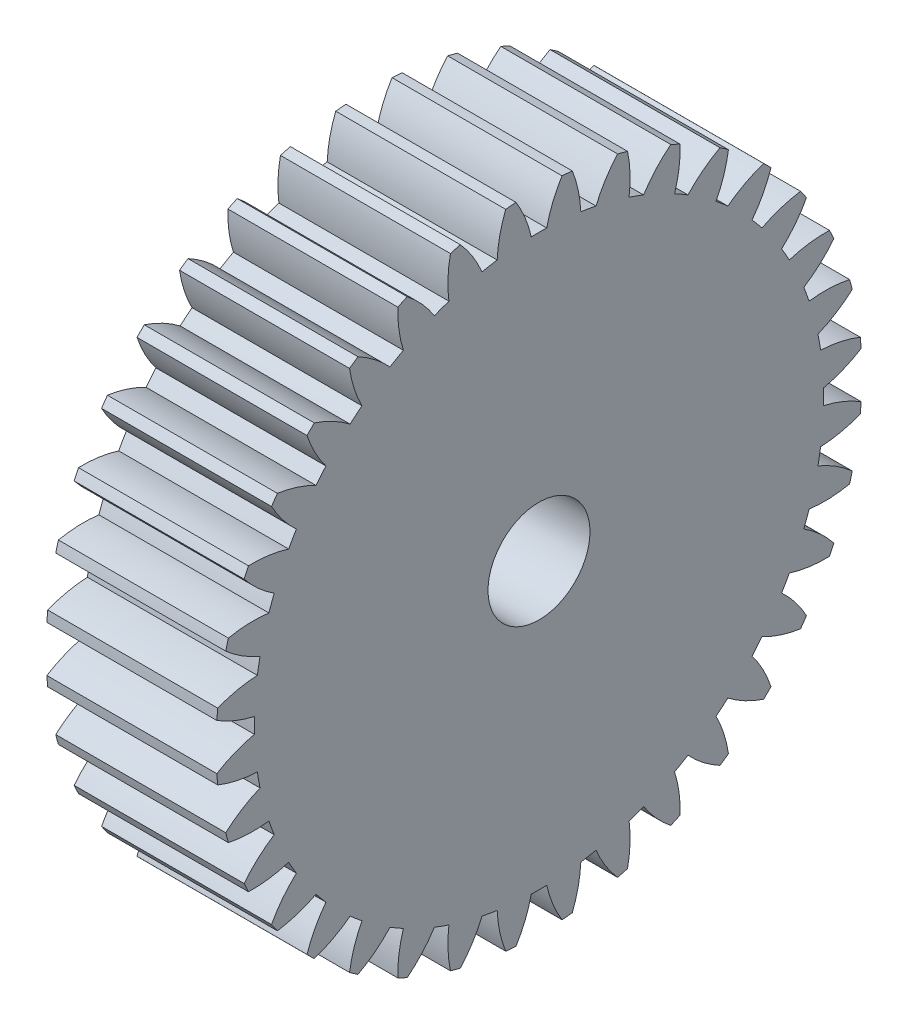
from build123d import *

# Parameters (mm, degrees)
BASPROSKE_W     = 10
BASPROSKE_H     = 19
TOOTHCUT_DEPTH  = 29.670542374
TEETHCUTS_COUNT = 36
TEETHCUTS_ANGLE = 350
BORSKE_R        = 3
BORE_DEPTH      = 50.0000508


with BuildPart() as part:
    # BasProSke → Base-Revolve (revolve)
    with BuildSketch(Plane(origin=(0, 0, 0), x_dir=(1, 0, 0), z_dir=(0, 1, 0)), mode=Mode.PRIVATE) as base_revolve_sk:
        with Locations((5, 9.5)):
            Rectangle(BASPROSKE_W, BASPROSKE_H)
    revolve(base_revolve_sk.sketch.rotate(Axis((-10, 0, 0), (1, 0, 0)), 180), axis=Axis((-10, 0, 0), (1, 0, 0)))

    # TooCutSke → ToothCut (cut, through all)
    with BuildSketch(Plane(origin=(0, 0, 0), x_dir=(0, 0, -1), z_dir=(1, 0, 0))):
        with BuildLine():
            ThreePointArc((0.454664826, 16.742827745), (0, 16.749), (-0.454664826, 16.742827745))
            ThreePointArc((-0.454664826, 16.742827745), (-0.817558311, 17.898033097), (-1.368909141, 18.976088452))
            ThreePointArc((-1.368909141, 18.976088452), (0, 19.0254), (1.368909141, 18.976088452))
            ThreePointArc((1.368909141, 18.976088452), (0.817558311, 17.898033097), (0.454664826, 16.742827745))
        make_face()
    toothcut = extrude(amount=TOOTHCUT_DEPTH, mode=Mode.SUBTRACT)

    # TeethCuts: ToothCut ×36 about axis
    teethcuts_axis = Axis((-10, 0, 0), (1, 0, 0))
    for i in range(1, TEETHCUTS_COUNT):
        add(toothcut.rotate(teethcuts_axis, i * TEETHCUTS_ANGLE / (TEETHCUTS_COUNT - 1)), mode=Mode.SUBTRACT)

    # BorSke → Bore (cut, symmetric)
    with BuildSketch(Plane(origin=(0, 0, 0), x_dir=(0, 0, -1), z_dir=(1, 0, 0))):
        with Locations(Location((0, 0, 0), (0, 0, 180))):
            Circle(BORSKE_R)
    extrude(amount=BORE_DEPTH, both=True, mode=Mode.SUBTRACT)


solid = part.part
